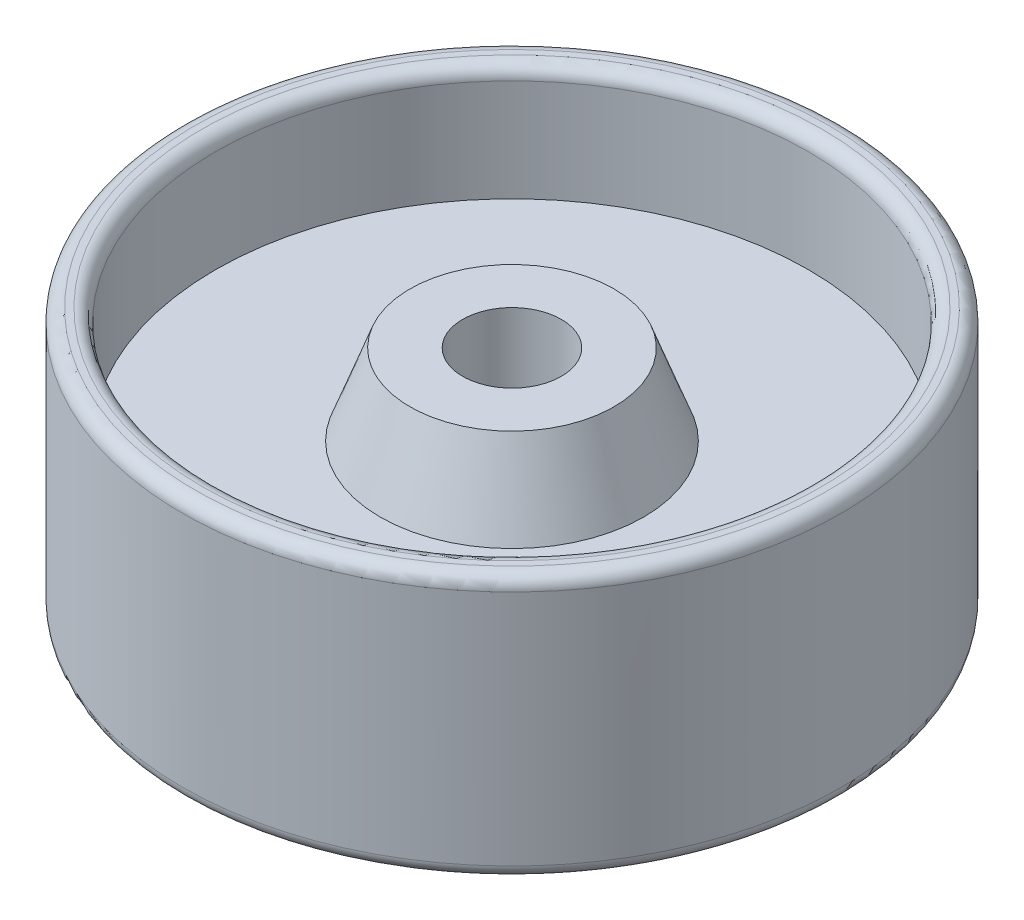
from build123d import *

# Parameters (mm, degrees)
FILLET1_R = 2.54


with BuildPart() as part:
    # Sketch1 → Revolve2 (revolve)
    with BuildSketch(Plane.XY):
        Polygon((0, -25.4), (0, 25.4), (6.35, 25.4), (6.35, 3.175), (38.1, 3.175), (43.827481803, 18.715945904), (53.987481803, 18.715945904), (53.987481803, -18.715945904), (43.149559422, -18.715945904), (38.1, -3.175), (6.35, -3.175), (6.35, -25.4), align=None)
    revolve(axis=Axis((63.5, 0, 0), (0, 1, 0)))

    # Fillet1
    fillet1_edges = [part.edges().sort_by_distance(p)[0] for p in [
        (120.65, 25.4, 0),
        (127, 25.4, 0),
        (127, -25.4, 0),
    ]]
    fillet(fillet1_edges, radius=FILLET1_R)


solid = part.part
